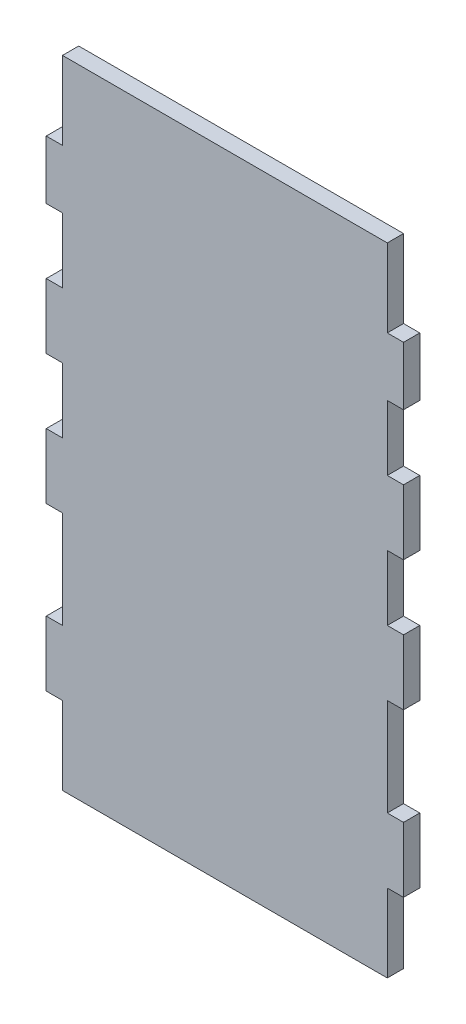
from build123d import *

# Parameters (mm, degrees)
SKETCH1_W           = 139.7
SKETCH1_H           = 246.38
BOSS_EXTRUDE1_DEPTH = 6.35
SKETCH2_W           = 6.35
SKETCH2_H           = 26.67
SKETCH2_H_2         = 38.1
SKETCH2_H_3         = 25.4
SKETCH2_H_4         = 31.75
CUT_EXTRUDE1_DEPTH  = 6.35
SKETCH7_W           = 6.35
SKETCH7_H           = 26.67
SKETCH7_H_2         = 38.1
SKETCH7_H_3         = 25.4
CUT_EXTRUDE5_DEPTH  = 7.35
SKETCH8_W           = 127
SKETCH8_H           = 6.35
BOSS_EXTRUDE2_DEPTH = 3.81
SKETCH6_W           = 6.35
SKETCH6_H           = 1.27
CUT_EXTRUDE6_DEPTH  = 134.35


with BuildPart() as part:
    # Sketch1 → Boss-Extrude1 (new body)
    with BuildSketch(Plane.XY):
        with Locations((-63.5, 129.54)):
            Rectangle(SKETCH1_W, SKETCH1_H)
    extrude(amount=BOSS_EXTRUDE1_DEPTH)

    # Sketch2 → Cut-Extrude1 (cut)
    with BuildSketch(Plane(origin=(6.35, 0, 0), x_dir=(0, 0, -1), z_dir=(1, 0, 0))):
        with Locations((-3.175, 19.685)):
            Rectangle(SKETCH2_W, SKETCH2_H)
        with Locations((-3.175, 77.47)):
            Rectangle(SKETCH2_W, SKETCH2_H_2)
        with Locations((-3.175, 134.62)):
            Rectangle(SKETCH2_W, SKETCH2_H_3)
        with Locations((-3.175, 185.42)):
            Rectangle(SKETCH2_W, SKETCH2_H_3)
        with Locations((-3.175, 236.855)):
            Rectangle(SKETCH2_W, SKETCH2_H_4)
    extrude(amount=-CUT_EXTRUDE1_DEPTH, mode=Mode.SUBTRACT)

    # Sketch7 → Cut-Extrude5 (cut, through all)
    with BuildSketch(Plane(origin=(0, 0, 0), x_dir=(-1, 0, 0), z_dir=(0, 0, -1))):
        with Locations((130.175, 19.685)):
            Rectangle(SKETCH7_W, SKETCH7_H)
        with Locations((130.175, 77.47)):
            Rectangle(SKETCH7_W, SKETCH7_H_2)
        with Locations((130.175, 134.62)):
            Rectangle(SKETCH7_W, SKETCH7_H_3)
        with Locations((130.175, 185.42)):
            Rectangle(SKETCH7_W, SKETCH7_H_3)
        Polygon((127, 220.98), (133.35, 220.98), (133.35, 252.73), (127, 252.73), (127, 247.65), align=None)
    extrude(amount=-CUT_EXTRUDE5_DEPTH, mode=Mode.SUBTRACT)

    # Sketch8 → Boss-Extrude2 (add)
    with BuildSketch(Plane.XZ.offset(-6.35)):
        with Locations((-63.5, 3.175)):
            Rectangle(SKETCH8_W, SKETCH8_H)
    extrude(amount=BOSS_EXTRUDE2_DEPTH)

    # Sketch6 → Cut-Extrude6 (cut, through all)
    with BuildSketch(Plane(origin=(0, 0, 0), x_dir=(0, 0, -1), z_dir=(1, 0, 0))):
        with Locations((-3.175, 252.095)):
            Rectangle(SKETCH6_W, SKETCH6_H)
    extrude(amount=-CUT_EXTRUDE6_DEPTH, mode=Mode.SUBTRACT)


solid = part.part
